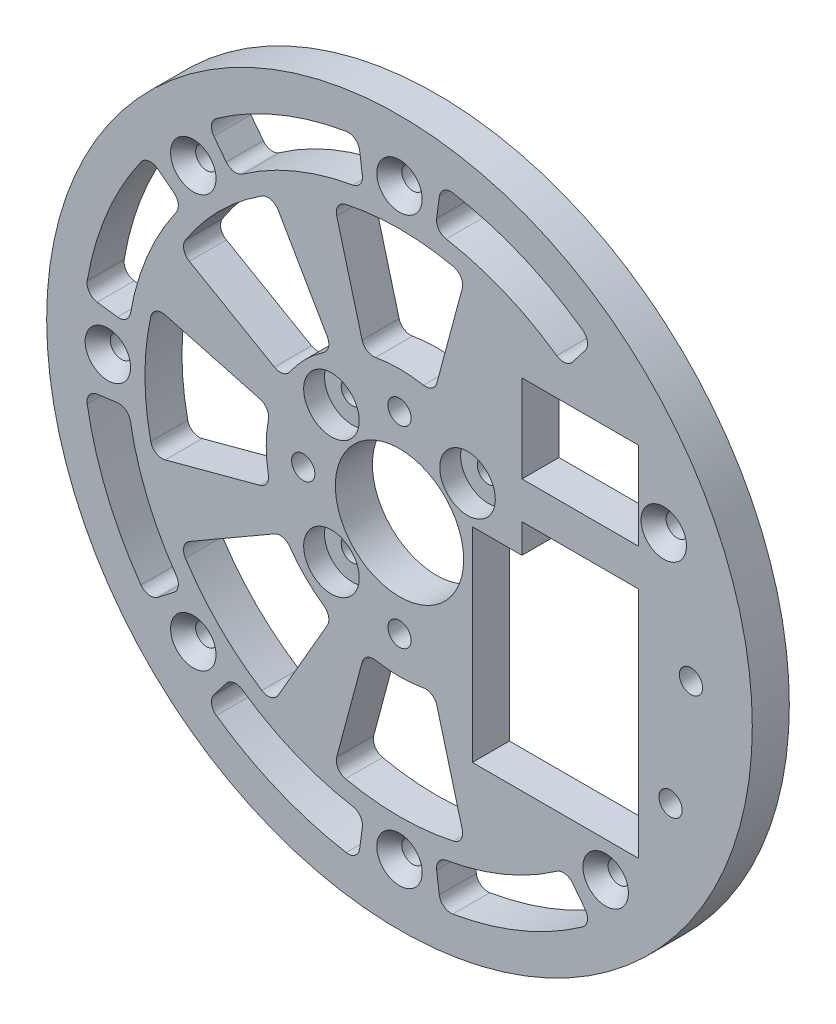
from build123d import *

# Parameters (mm, degrees)
SKETCH1_R                = 60.5
SKETCH1_R_2              = 1.89865
SKETCH1_R_3              = 1.9939
SKETCH1_R_4              = 11
BOSS_EXTRUDE1_DEPTH      = 6.35
SKETCH2_W                = 20
SKETCH2_H                = 15
CUT_EXTRUDE1_DEPTH       = 7.35
CUT_EXTRUDE2_DEPTH       = 7.35
FILLET1_R                = 2
CIRPATTERN1_COUNT        = 8
FILLET1_OF_CIRPATTERN1_R = 2
SKETCH4_R                = 1.89865
CUT_EXTRUDE3_DEPTH       = 7.35
FILLET2_R                = 2
CIRPATTERN2_COUNT        = 8
FILLET2_OF_CIRPATTERN2_R = 2
CHAMFER1_SIZE            = 2.301024407
CHAMFER1_SIZE2           = 2.00025
CHAMFER1_PART_2_SIZE     = 2.301024407
CHAMFER1_PART_2_SIZE2    = 2.00025
CHAMFER1_PART_3_SIZE     = 2.301024407
CHAMFER1_PART_3_SIZE2    = 2.00025
CHAMFER1_PART_4_SIZE     = 2.301024407
CHAMFER1_PART_4_SIZE2    = 2.00025
CHAMFER1_PART_5_SIZE     = 2.301024407
CHAMFER1_PART_5_SIZE2    = 2.00025
CHAMFER1_PART_6_SIZE     = 2.301024407
CHAMFER1_PART_6_SIZE2    = 2.00025
CHAMFER1_PART_7_SIZE     = 2.301024407
CHAMFER1_PART_7_SIZE2    = 2.00025
SKETCH5_R                = 4.7625
SKETCH5_R_2              = 1.89865
CUT_EXTRUDE4_DEPTH       = 3.571875


with BuildPart() as part:
    # Sketch1 → Boss-Extrude1 (new body)
    with BuildSketch(Plane.XY):
        Circle(SKETCH1_R)
        with Locations((45.315389352, 21.130913087)):
            Circle(SKETCH1_R_2, mode=Mode.SUBTRACT)
        with Locations((49.978847504, 1.454235937)):
            Circle(SKETCH1_R_3, mode=Mode.SUBTRACT)
        Circle(SKETCH1_R_4, mode=Mode.SUBTRACT)
        with Locations((46.467376211, -18.460307366)):
            Circle(SKETCH1_R_3, mode=Mode.SUBTRACT)
        with Locations((0, -16.5)):
            Circle(SKETCH1_R_3, mode=Mode.SUBTRACT)
        with Locations((0, -50)):
            Circle(SKETCH1_R_2, mode=Mode.SUBTRACT)
        with Locations((-16.5, 0)):
            Circle(SKETCH1_R_3, mode=Mode.SUBTRACT)
        with Locations((-11.66726189, -11.66726189)):
            Circle(SKETCH1_R_2, mode=Mode.SUBTRACT)
        with Locations((0, 16.5)):
            Circle(SKETCH1_R_3, mode=Mode.SUBTRACT)
        with Locations((-11.66726189, 11.66726189)):
            Circle(SKETCH1_R_2, mode=Mode.SUBTRACT)
        with Locations((11.66726189, 11.66726189)):
            Circle(SKETCH1_R_2, mode=Mode.SUBTRACT)
        with Locations((-35.355339059, -35.355339059)):
            Circle(SKETCH1_R_2, mode=Mode.SUBTRACT)
        with Locations((-50, 0)):
            Circle(SKETCH1_R_2, mode=Mode.SUBTRACT)
        with Locations((-35.355339059, 35.355339059)):
            Circle(SKETCH1_R_2, mode=Mode.SUBTRACT)
        with Locations((0, 50)):
            Circle(SKETCH1_R_2, mode=Mode.SUBTRACT)
        with Locations((35.355339059, -35.355339059)):
            Circle(SKETCH1_R_2, mode=Mode.SUBTRACT)
    extrude(amount=BOSS_EXTRUDE1_DEPTH)

    # Sketch2 → Cut-Extrude1 (cut, through all)
    with BuildSketch(Plane.XY):
        Polygon((12.5, -29.35), (41, -29.35), (41, 10.65), (21, 10.65), (21, 5.65), (12.5, 5.65), align=None)
        with Locations((31, 24.5)):
            Rectangle(SKETCH2_W, SKETCH2_H)
    extrude(amount=CUT_EXTRUDE1_DEPTH, mode=Mode.SUBTRACT)

    # Sketch3 → Cut-Extrude2 (cut, through all)
    with BuildSketch(Plane.XY.offset(6.35)):
        with BuildLine():
            Line((-42.162662318, -11.297451319), (-22.071405131, -5.914015181))
            ThreePointArc((-22.071405131, -5.914015181), (-22.85, 0), (-22.071405131, 5.914015181))
            Line((-22.071405131, 5.914015181), (-42.162662318, 11.297451319))
            ThreePointArc((-42.162662318, 11.297451319), (-43.65, 0), (-42.162662318, -11.297451319))
        make_face()
    cut_extrude2 = extrude(amount=-CUT_EXTRUDE2_DEPTH, mode=Mode.SUBTRACT)

    # Fillet1
    fillet1_edges = [part.edges().sort_by_distance(p)[0] for p in [
        (-22.071405131, 5.914015181, 3.175),
        (-22.071405131, -5.914015181, 3.175),
        (-42.162662318, -11.297451319, 3.175),
        (-42.162662318, 11.297451319, 3.175),
    ]]
    fillet(fillet1_edges, radius=FILLET1_R)

    # CirPattern1: Cut-Extrude2 ×8 about axis, 3 skipped
    cirpattern1_axis = Axis((0, 0, 0), (0, 0, -1))
    add([cut_extrude2.rotate(cirpattern1_axis, i * 360 / CIRPATTERN1_COUNT) for i in range(1, CIRPATTERN1_COUNT) if i not in (3, 4, 5)], mode=Mode.SUBTRACT)

    # Fillet1 of CirPattern1
    fillet1_of_cirpattern1_edges = [part.edges().sort_by_distance(p)[0] for p in [
        (-11.425, 19.788680476, 3.175),
        (-19.788680476, 11.425, 3.175),
        (-37.802008875, 21.825, 3.175),
        (-21.825, 37.802008875, 3.175),
        (5.914015181, 22.071405131, 3.175),
        (-5.914015181, 22.071405131, 3.175),
        (-11.297451319, 42.162662318, 3.175),
        (11.297451319, 42.162662318, 3.175),
        (-5.914015181, -22.071405131, 3.175),
        (5.914015181, -22.071405131, 3.175),
        (11.297451319, -42.162662318, 3.175),
        (-11.297451319, -42.162662318, 3.175),
        (-19.788680476, -11.425, 3.175),
        (-11.425, -19.788680476, 3.175),
        (-21.825, -37.802008875, 3.175),
        (-37.802008875, -21.825, 3.175),
    ]]
    fillet(fillet1_of_cirpattern1_edges, radius=FILLET1_OF_CIRPATTERN1_R)

    # Sketch4 → Cut-Extrude3 (cut, through all)
    with BuildSketch(Plane.XY.offset(6.35)):
        with Locations((-50, 0)):
            Circle(SKETCH4_R)
        with BuildLine():
            Line((-43.098920211, 33.070964631), (-37.148770159, 28.505253913))
            ThreePointArc((-37.148770159, 28.505253913), (-43.26065911, 17.91915172), (-46.424405634, 6.111888951))
            Line((-46.424405634, 6.111888951), (-53.860242094, 7.090835392))
            ThreePointArc((-53.860242094, 7.090835392), (-50.189755604, 20.789277463), (-43.098920211, 33.070964631))
        make_face()
    cut_extrude3 = extrude(amount=-CUT_EXTRUDE3_DEPTH, mode=Mode.SUBTRACT)

    # Fillet2
    fillet2_edges = [part.edges().sort_by_distance(p)[0] for p in [
        (-37.148770159, 28.505253913, 3.175),
        (-46.424405634, 6.111888951, 3.175),
        (-53.860242094, 7.090835392, 3.175),
        (-43.098920211, 33.070964631, 3.175),
    ]]
    fillet(fillet2_edges, radius=FILLET2_R)

    # CirPattern2: Cut-Extrude3 ×8 about axis, 2 skipped
    cirpattern2_axis = Axis((0, 0, 0), (0, 0, -1))
    add([cut_extrude3.rotate(cirpattern2_axis, i * 360 / CIRPATTERN2_COUNT) for i in range(1, CIRPATTERN2_COUNT) if i not in (3, 4)], mode=Mode.SUBTRACT)

    # Fillet2 of CirPattern2
    fillet2_of_cirpattern2_edges = [part.edges().sort_by_distance(p)[0] for p in [
        (-6.111888951, 46.424405634, 3.175),
        (-28.505253913, 37.148770159, 3.175),
        (-33.070964631, 43.098920211, 3.175),
        (-7.090835392, 53.860242094, 3.175),
        (28.505253913, 37.148770159, 3.175),
        (6.111888951, 46.424405634, 3.175),
        (7.090835392, 53.860242094, 3.175),
        (33.070964631, 43.098920211, 3.175),
        (6.111888951, -46.424405634, 3.175),
        (28.505253913, -37.148770159, 3.175),
        (33.070964631, -43.098920211, 3.175),
        (7.090835392, -53.860242094, 3.175),
        (-28.505253913, -37.148770159, 3.175),
        (-6.111888951, -46.424405634, 3.175),
        (-7.090835392, -53.860242094, 3.175),
        (-33.070964631, -43.098920211, 3.175),
        (-46.424405634, -6.111888951, 3.175),
        (-37.148770159, -28.505253913, 3.175),
        (-43.098920211, -33.070964631, 3.175),
        (-53.860242094, -7.090835392, 3.175),
    ]]
    fillet(fillet2_of_cirpattern2_edges, radius=FILLET2_OF_CIRPATTERN2_R)

    # Chamfer1
    chamfer1_edges = [part.edges().sort_by_distance(p)[0] for p in [
        (-1.89865, -50, 6.35),
    ]]
    chamfer1_side = [part.faces().sort_by_distance(p)[0] for p in [
        (-1.89865, -50, 3.175),
    ]]
    chamfer(chamfer1_edges, length=CHAMFER1_SIZE, length2=CHAMFER1_SIZE2, reference=chamfer1_side[0])

    # Chamfer1 part 2
    chamfer1_part_2_edges = [part.edges().sort_by_distance(p)[0] for p in [
        (-37.253989059, -35.355339059, 6.35),
    ]]
    chamfer1_part_2_side = [part.faces().sort_by_distance(p)[0] for p in [
        (-37.253989059, -35.355339059, 3.175),
    ]]
    chamfer(chamfer1_part_2_edges, length=CHAMFER1_PART_2_SIZE, length2=CHAMFER1_PART_2_SIZE2, reference=chamfer1_part_2_side[0])

    # Chamfer1 part 3
    chamfer1_part_3_edges = [part.edges().sort_by_distance(p)[0] for p in [
        (-51.89865, 0, 6.35),
    ]]
    chamfer1_part_3_side = [part.faces().sort_by_distance(p)[0] for p in [
        (-51.89865, 0, 3.175),
    ]]
    chamfer(chamfer1_part_3_edges, length=CHAMFER1_PART_3_SIZE, length2=CHAMFER1_PART_3_SIZE2, reference=chamfer1_part_3_side[0])

    # Chamfer1 part 4
    chamfer1_part_4_edges = [part.edges().sort_by_distance(p)[0] for p in [
        (43.416739352, 21.130913087, 6.35),
    ]]
    chamfer1_part_4_side = [part.faces().sort_by_distance(p)[0] for p in [
        (43.416739352, 21.130913087, 3.175),
    ]]
    chamfer(chamfer1_part_4_edges, length=CHAMFER1_PART_4_SIZE, length2=CHAMFER1_PART_4_SIZE2, reference=chamfer1_part_4_side[0])

    # Chamfer1 part 5
    chamfer1_part_5_edges = [part.edges().sort_by_distance(p)[0] for p in [
        (-37.253989059, 35.355339059, 6.35),
    ]]
    chamfer1_part_5_side = [part.faces().sort_by_distance(p)[0] for p in [
        (-37.253989059, 35.355339059, 3.175),
    ]]
    chamfer(chamfer1_part_5_edges, length=CHAMFER1_PART_5_SIZE, length2=CHAMFER1_PART_5_SIZE2, reference=chamfer1_part_5_side[0])

    # Chamfer1 part 6
    chamfer1_part_6_edges = [part.edges().sort_by_distance(p)[0] for p in [
        (-1.89865, 50, 6.35),
    ]]
    chamfer1_part_6_side = [part.faces().sort_by_distance(p)[0] for p in [
        (-1.89865, 50, 3.175),
    ]]
    chamfer(chamfer1_part_6_edges, length=CHAMFER1_PART_6_SIZE, length2=CHAMFER1_PART_6_SIZE2, reference=chamfer1_part_6_side[0])

    # Chamfer1 part 7
    chamfer1_part_7_edges = [part.edges().sort_by_distance(p)[0] for p in [
        (33.456689059, -35.355339059, 6.35),
    ]]
    chamfer1_part_7_side = [part.faces().sort_by_distance(p)[0] for p in [
        (33.456689059, -35.355339059, 3.175),
    ]]
    chamfer(chamfer1_part_7_edges, length=CHAMFER1_PART_7_SIZE, length2=CHAMFER1_PART_7_SIZE2, reference=chamfer1_part_7_side[0])

    # Sketch5 → Cut-Extrude4 (cut)
    with BuildSketch(Plane.XY.offset(6.35)):
        with Locations((11.66726189, 11.66726189)):
            Circle(SKETCH5_R)
        with Locations((11.66726189, 11.66726189)):
            Circle(SKETCH5_R_2, mode=Mode.SUBTRACT)
        with Locations((-11.66726189, 11.66726189)):
            Circle(SKETCH5_R)
        with Locations((-11.66726189, 11.66726189)):
            Circle(SKETCH5_R_2, mode=Mode.SUBTRACT)
        with Locations((-11.66726189, -11.66726189)):
            Circle(SKETCH5_R)
        with Locations((-11.66726189, -11.66726189)):
            Circle(SKETCH5_R_2, mode=Mode.SUBTRACT)
    extrude(amount=-CUT_EXTRUDE4_DEPTH, mode=Mode.SUBTRACT)


solid = part.part
